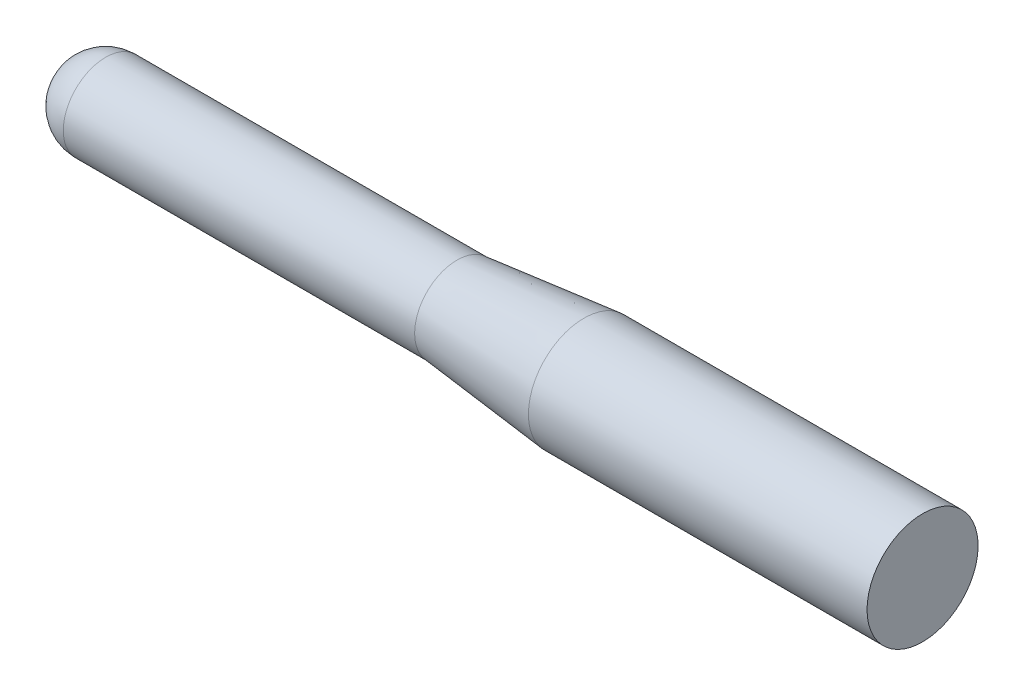
from build123d import *


with BuildPart() as part:
    # Sketch1 → Revolve1 (revolve)
    with BuildSketch(Plane.XY):
        with BuildLine():
            Line((12.7, 12.7), (118.11, 12.7))
            Line((118.11, 12.7), (156.210003035, 16.662289952))
            Line((156.210003035, 16.662289952), (257.810003035, 16.662289952))
            Line((257.810003035, 16.662289952), (257.810003035, 0))
            Line((257.810003035, 0), (0, 0))
            ThreePointArc((0, 0), (3.719743879, 8.980256121), (12.7, 12.7))
        make_face()
    revolve(axis=Axis((0, 0, 0), (1, 0, 0)))


solid = part.part
